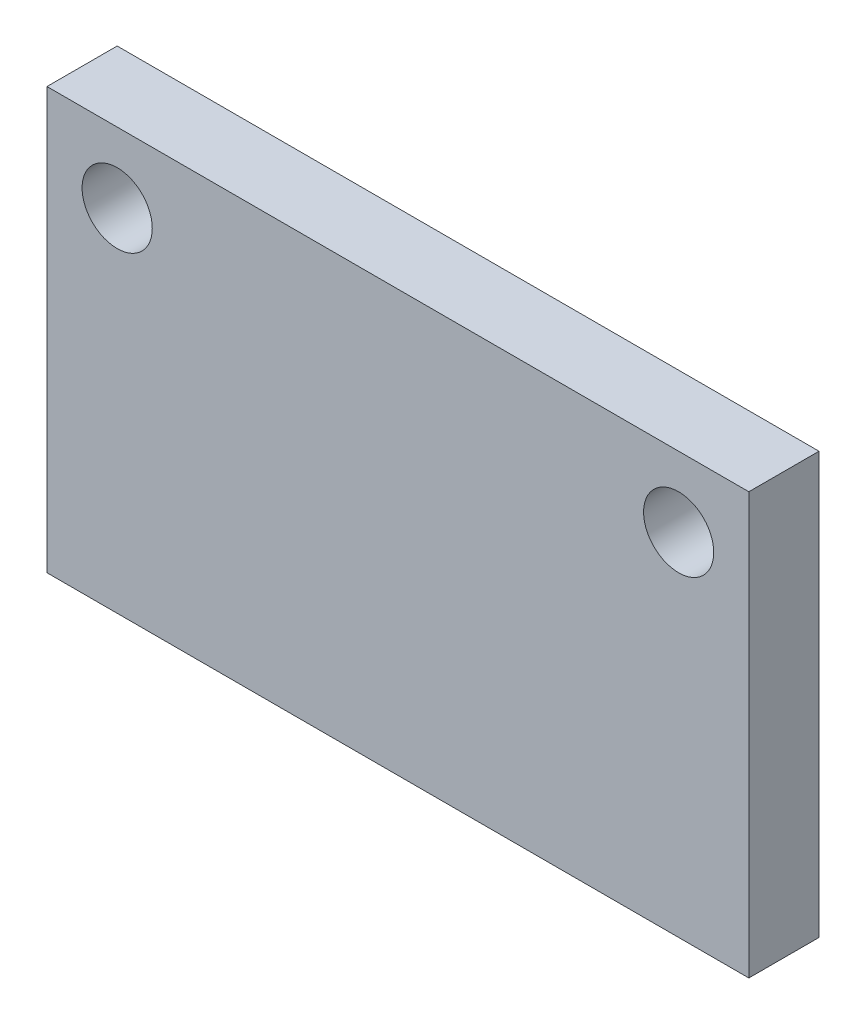
from build123d import *

# Parameters (mm, degrees)
SKETCH1_W           = 25.4
SKETCH1_H           = 15.24
SKETCH1_R           = 1.27
BOSS_EXTRUDE1_DEPTH = 2.54


with BuildPart() as part:
    # Sketch1 → Boss-Extrude1 (new body)
    with BuildSketch(Plane.XY):
        Rectangle(SKETCH1_W, SKETCH1_H)
        with Locations((-10.16, 5.08)):
            Circle(SKETCH1_R, mode=Mode.SUBTRACT)
        with Locations((10.16, 5.08)):
            Circle(SKETCH1_R, mode=Mode.SUBTRACT)
    extrude(amount=BOSS_EXTRUDE1_DEPTH)


solid = part.part
